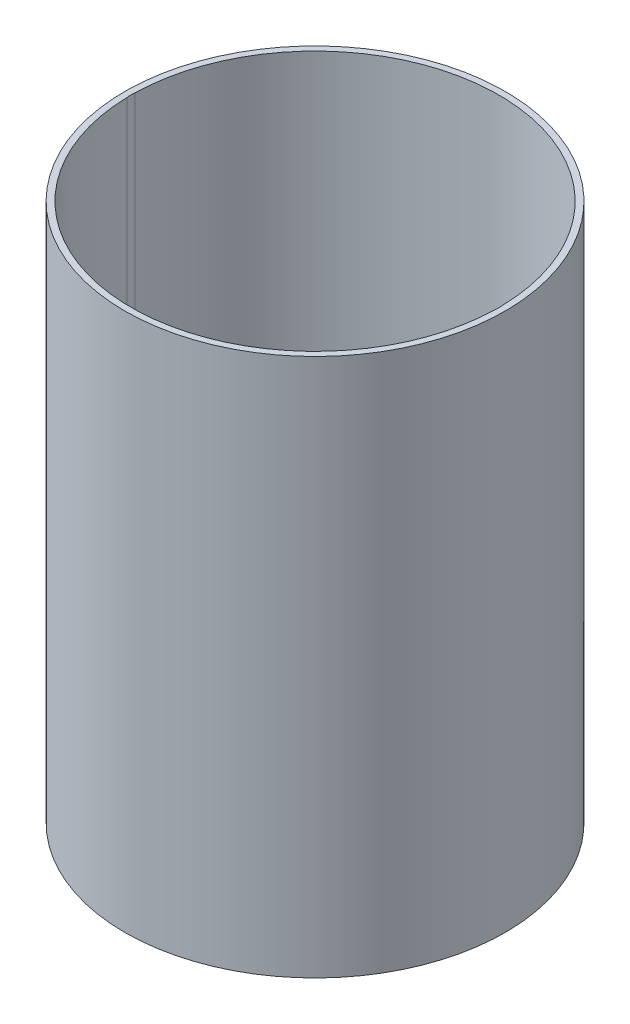
from build123d import *

# Parameters (mm, degrees)
SKETCH1_R               = 92.71
SKETCH1_R_2             = 53.975
TOP_OF_HATCH_DEPTH      = 3.302
SKETCH2_R               = 92.71
SKETCH2_R_2             = 89.662
HATCH_BODY_DEPTH        = 259.08
SKETCH3_R               = 13.335
CHARGE_TUBE_HOLES_DEPTH = 263.382
SKETCH4_R               = 3.81
BOLT_HOLES_DEPTH        = 263.382
SKETCH_5_R              = 5.08
ANTENNA_HOLES_DEPTH     = 263.382


with BuildPart() as part:
    # Sketch1 → Top of Hatch (new body)
    with BuildSketch(Plane(origin=(0, 0, 0), x_dir=(1, 0, 0), z_dir=(0, 1, 0))):
        Circle(SKETCH1_R)
        Circle(SKETCH1_R_2, mode=Mode.SUBTRACT)
    extrude(amount=TOP_OF_HATCH_DEPTH)

    # Sketch2 → Hatch Body (add)
    with BuildSketch(Plane(origin=(0, 3.302, 0), x_dir=(1, 0, 0), z_dir=(0, 1, 0))):
        Circle(SKETCH2_R)
        Circle(SKETCH2_R_2, mode=Mode.SUBTRACT)
    extrude(amount=HATCH_BODY_DEPTH)

    # Sketch3 → Charge Tube Holes (cut, through all)
    with BuildSketch(Plane.XZ):
        with Locations((-76.454, 0)):
            Circle(SKETCH3_R)
        with Locations((76.454, 0)):
            Circle(SKETCH3_R)
    extrude(amount=-CHARGE_TUBE_HOLES_DEPTH, mode=Mode.SUBTRACT)

    # Sketch4 → Bolt Holes (cut, through all)
    with BuildSketch(Plane.XZ):
        with Locations((38.1, 65.991135768)):
            Circle(SKETCH4_R)
        with Locations((-38.1, 65.991135768)):
            Circle(SKETCH4_R)
        with Locations((-38.1, -65.991135768)):
            Circle(SKETCH4_R)
        with Locations((38.1, -65.991135768)):
            Circle(SKETCH4_R)
    extrude(amount=-BOLT_HOLES_DEPTH, mode=Mode.SUBTRACT)

    # Sketch 5 → Antenna Holes (cut, through all)
    with BuildSketch(Plane.XZ):
        with Locations((-26.112352144, 57.324838678)):
            Circle(SKETCH_5_R)
        with Locations((9.193647856, 61.033450854)):
            Circle(SKETCH_5_R)
    extrude(amount=-ANTENNA_HOLES_DEPTH, mode=Mode.SUBTRACT)


solid = part.part
